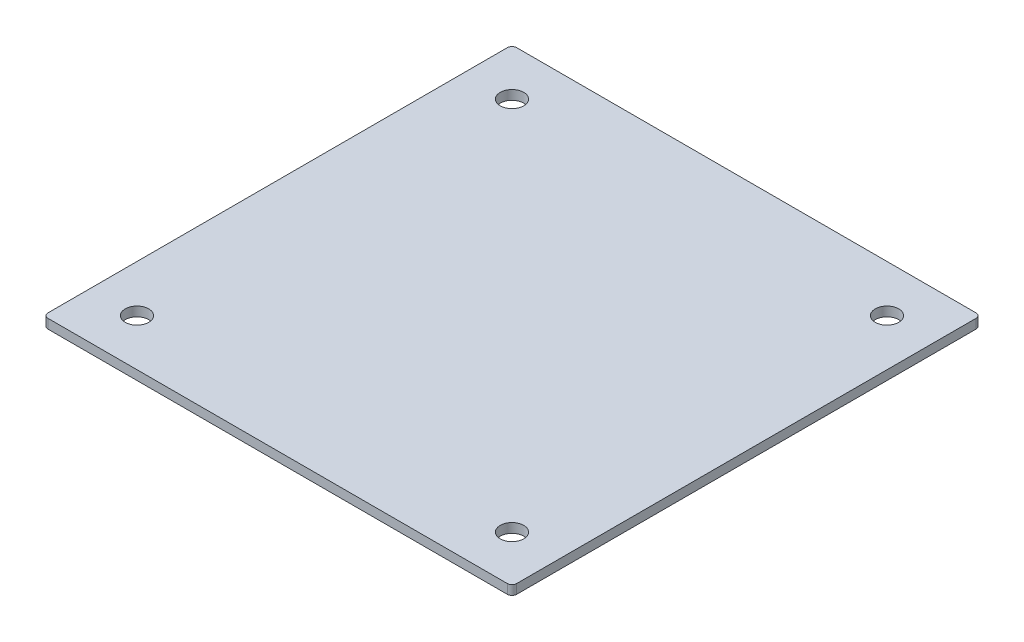
from build123d import *

# Parameters (mm, degrees)
SKETCH1_R           = 5
BOSS_EXTRUDE1_DEPTH = 4


with BuildPart() as part:
    # Sketch1 → Boss-Extrude1 (new body)
    with BuildSketch(Plane(origin=(0, 0, 0), x_dir=(1, 0, 0), z_dir=(0, 1, 0))):
        with BuildLine():
            Line((-98, -100), (98, -100))
            ThreePointArc((98, -100), (99.414213562, -99.414213562), (100, -98))
            Line((100, -98), (100, 98))
            ThreePointArc((100, 98), (99.414213562, 99.414213562), (98, 100))
            Line((98, 100), (-98, 100))
            ThreePointArc((-98, 100), (-99.414213562, 99.414213562), (-100, 98))
            Line((-100, 98), (-100, -98))
            ThreePointArc((-100, -98), (-99.414213562, -99.414213562), (-98, -100))
        make_face()
        with Locations((-80, -80)):
            Circle(SKETCH1_R, mode=Mode.SUBTRACT)
        with Locations((80, -80)):
            Circle(SKETCH1_R, mode=Mode.SUBTRACT)
        with Locations((80, 80)):
            Circle(SKETCH1_R, mode=Mode.SUBTRACT)
        with Locations((-80, 80)):
            Circle(SKETCH1_R, mode=Mode.SUBTRACT)
    extrude(amount=BOSS_EXTRUDE1_DEPTH)


solid = part.part
